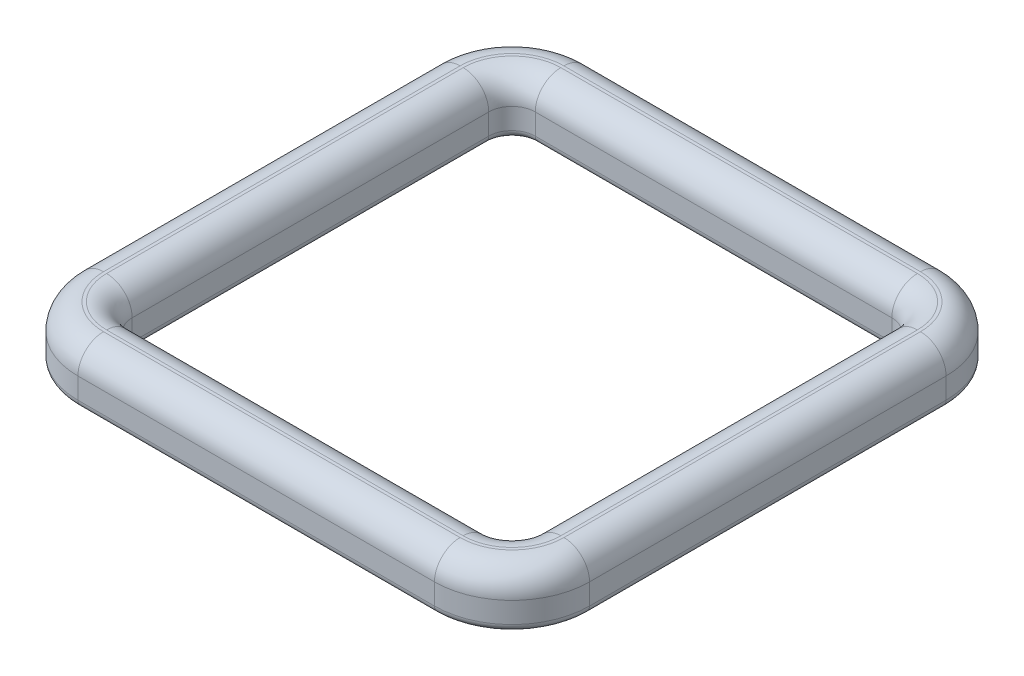
from build123d import *

# Parameters (mm, degrees)
BOSS_EXTRUDE1_DEPTH = 8.89
FILLET1_R           = 4.191
FILLET2_R           = 1.27


with BuildPart() as part:
    # Sketch1 → Boss-Extrude1 (new body)
    with BuildSketch(Plane(origin=(0, 0, 0), x_dir=(1, 0, 0), z_dir=(0, 1, 0))):
        with BuildLine():
            Line((-8.89, 3.81), (-8.89, 62.23))
            ThreePointArc((-8.89, 62.23), (-5.170256121, 71.210256121), (3.81, 74.93))
            Line((3.81, 74.93), (62.23, 74.93))
            ThreePointArc((62.23, 74.93), (71.210256121, 71.210256121), (74.93, 62.23))
            Line((74.93, 62.23), (74.93, 3.81))
            ThreePointArc((74.93, 3.81), (71.210256121, -5.170256121), (62.23, -8.89))
            Line((62.23, -8.89), (3.81, -8.89))
            ThreePointArc((3.81, -8.89), (-5.170256121, -5.170256121), (-8.89, 3.81))
        make_face()
        with BuildLine():
            Line((3.81, 0), (62.23, 0))
            ThreePointArc((62.23, 0), (64.924076836, 1.115923164), (66.04, 3.81))
            Line((66.04, 3.81), (66.04, 62.23))
            ThreePointArc((66.04, 62.23), (64.924076836, 64.924076836), (62.23, 66.04))
            Line((62.23, 66.04), (3.81, 66.04))
            ThreePointArc((3.81, 66.04), (1.115923164, 64.924076836), (0, 62.23))
            Line((0, 62.23), (0, 3.81))
            ThreePointArc((0, 3.81), (1.115923164, 1.115923164), (3.81, 0))
        make_face(mode=Mode.SUBTRACT)
    extrude(amount=BOSS_EXTRUDE1_DEPTH)

    # Fillet1
    fillet1_edges = [part.edges().sort_by_distance(p)[0] for p in [
        (71.210256121, 8.89, 5.170256121),
        (74.93, 8.89, -33.02),
        (71.210256121, 8.89, -71.210256121),
        (33.02, 8.89, -74.93),
        (-5.170256121, 8.89, -71.210256121),
        (-8.89, 8.89, -33.02),
        (1.115923164, 8.89, -1.115923164),
        (33.02, 8.89, 0),
        (64.924076836, 8.89, -1.115923164),
        (66.04, 8.89, -33.02),
        (64.924076836, 8.89, -64.924076836),
        (33.02, 8.89, -66.04),
        (1.115923164, 8.89, -64.924076836),
        (0, 8.89, -33.02),
        (-5.170256121, 8.89, 5.170256121),
        (33.02, 8.89, 8.89),
    ]]
    fillet(fillet1_edges, radius=FILLET1_R)

    # Fillet2
    fillet2_edges = [part.edges().sort_by_distance(p)[0] for p in [
        (33.02, 0, 8.89),
        (-5.170256121, 0, 5.170256121),
        (1.115923164, 0, -1.115923164),
        (33.02, 0, 0),
        (64.924076836, 0, -1.115923164),
        (66.04, 0, -33.02),
        (64.924076836, 0, -64.924076836),
        (33.02, 0, -66.04),
        (1.115923164, 0, -64.924076836),
        (0, 0, -33.02),
        (-8.89, 0, -33.02),
        (-5.170256121, 0, -71.210256121),
        (33.02, 0, -74.93),
        (71.210256121, 0, -71.210256121),
        (74.93, 0, -33.02),
        (71.210256121, 0, 5.170256121),
    ]]
    fillet(fillet2_edges, radius=FILLET2_R)


solid = part.part
